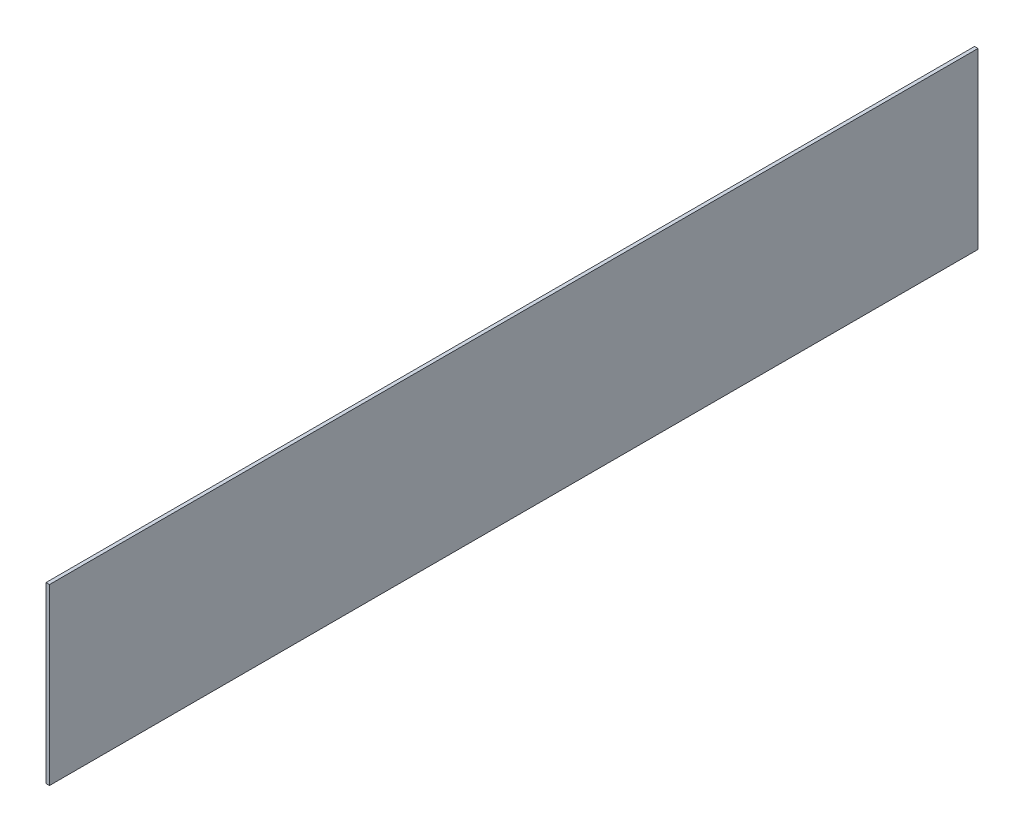
from build123d import *

# Parameters (mm, degrees)
SKETCH1_W           = 800
SKETCH1_H           = 150
BOSS_EXTRUDE1_DEPTH = 3


with BuildPart() as part:
    # Sketch1 → Boss-Extrude1 (new body)
    with BuildSketch(Plane(origin=(0, 0, 0), x_dir=(0, 0, -1), z_dir=(1, 0, 0))):
        Rectangle(SKETCH1_W, SKETCH1_H)
    extrude(amount=BOSS_EXTRUDE1_DEPTH)


solid = part.part
